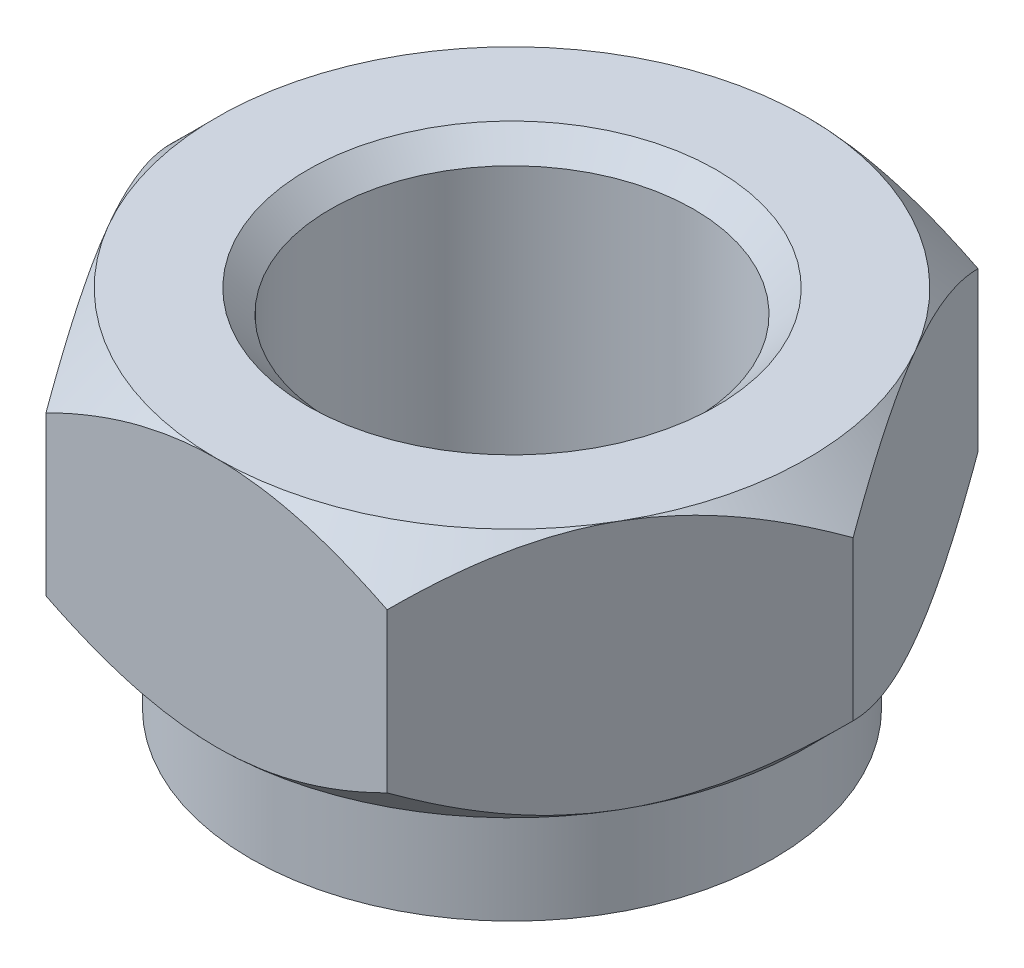
from build123d import *

# Parameters (mm, degrees)
SZKIC1_R                    = 4
DODANIE_WYCI_GNI_CIE1_DEPTH = 5.5
SZKIC2_OUTSIDE_W            = 34.134
SZKIC2_OUTSIDE_H            = 32.122
SZKIC2_OUTSIDE_R            = 6.5
WYTNIJ_WYCI_GNI_CIE29_DEPTH = 6.5
WYTNIJ_WYCI_GNI_CIE29_TAPER = 45
SZKIC4_R                    = 5.75
SZKIC4_R_2                  = 4
DODANIE_WYCI_GNI_CIE2_DEPTH = 2.5
SZKIC5_OUTSIDE_W            = 41.294
SZKIC5_OUTSIDE_H            = 39.282
SZKIC5_OUTSIDE_R            = 6.5
WYTNIJ_WYCI_GNI_CIE30_DEPTH = 10
WYTNIJ_WYCI_GNI_CIE30_TAPER = 45
ZAOKR_GLENIE1_R             = 0.1
SFAZOWANIE1_SIZE            = 0.5


with BuildPart() as part:
    # Szkic1 → Dodanie-wyciągnięcie1 (new body)
    with BuildSketch(Plane(origin=(0, 0, 0), x_dir=(1, 0, 0), z_dir=(0, 1, 0))):
        Polygon((7.505553499, 0), (3.75277675, 6.5), (-3.75277675, 6.5), (-7.505553499, 0), (-3.75277675, -6.5), (3.75277675, -6.5), align=None)
        Circle(SZKIC1_R, mode=Mode.SUBTRACT)
    extrude(amount=DODANIE_WYCI_GNI_CIE1_DEPTH)

    # Szkic2 outside → Wytnij-wyciągnięcie29 (cut, through all)
    with BuildSketch(Plane(origin=(0, 5.5, 0), x_dir=(1, 0, 0), z_dir=(0, 1, 0))):
        Rectangle(SZKIC2_OUTSIDE_W, SZKIC2_OUTSIDE_H)
        Circle(SZKIC2_OUTSIDE_R, mode=Mode.SUBTRACT)
    extrude(amount=-WYTNIJ_WYCI_GNI_CIE29_DEPTH, taper=WYTNIJ_WYCI_GNI_CIE29_TAPER, mode=Mode.SUBTRACT)

    # Szkic4 → Dodanie-wyciągnięcie2 (add)
    with BuildSketch(Plane(origin=(0, 0, 0), x_dir=(-1, 0, 0), z_dir=(0, -1, 0))):
        Circle(SZKIC4_R)
        Circle(SZKIC4_R_2, mode=Mode.SUBTRACT)
    extrude(amount=DODANIE_WYCI_GNI_CIE2_DEPTH)

    # Szkic5 outside → Wytnij-wyciągnięcie30 (cut)
    with BuildSketch(Plane(origin=(0, 0, 0), x_dir=(-1, 0, 0), z_dir=(0, -1, 0))):
        Rectangle(SZKIC5_OUTSIDE_W, SZKIC5_OUTSIDE_H)
        Circle(SZKIC5_OUTSIDE_R, mode=Mode.SUBTRACT)
    extrude(amount=-WYTNIJ_WYCI_GNI_CIE30_DEPTH, taper=WYTNIJ_WYCI_GNI_CIE30_TAPER, mode=Mode.SUBTRACT)

    # Zaokrąglenie1
    zaokr_glenie1_edges = [part.edges().sort_by_distance(p)[0] for p in [
        (5.75, 0, 0),
    ]]
    fillet(zaokr_glenie1_edges, radius=ZAOKR_GLENIE1_R)

    # Sfazowanie1
    sfazowanie1_edges = [part.edges().sort_by_distance(p)[0] for p in [
        (-4, 5.5, 0),
        (4, -2.5, 0),
    ]]
    chamfer(sfazowanie1_edges, length=SFAZOWANIE1_SIZE)


solid = part.part
